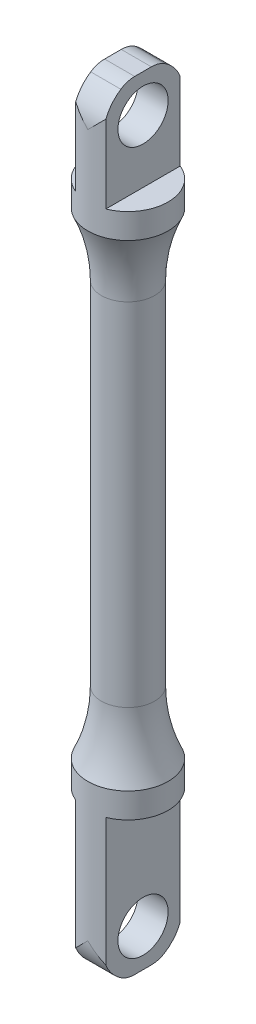
from build123d import *

# Parameters (mm, degrees)
BOSS_EXTRUDE1_DEPTH     = 20
BOSS_EXTRUDE2_DEPTH     = 30
SKETCH5_R               = 5
CUT_EXTRUDE1_DEPTH      = 6
CUT_EXTRUDE1_DEPTH_BACK = 12
FILLET6_R               = 5


with BuildPart() as part:
    # Sketch1 → Revolve1 (revolve)
    with BuildSketch(Plane.XY, mode=Mode.PRIVATE) as revolve1_sk:
        with BuildLine():
            Line((0, 0), (0, -52.5))
            Line((0, -52.5), (8, -52.5))
            Line((8, -52.5), (8, -47.5))
            ThreePointArc((8, -47.5), (5.982694721, -41.39413794), (5.3, -35))
            Line((5.3, -35), (5.3, 0))
            Line((5.3, 0), (0, 0))
        make_face()
    revolve1 = revolve(revolve1_sk.sketch.rotate(Axis((0, 0, 0), (0, -1, 0)), 180), axis=Axis((0, 0, 0), (0, -1, 0)))  # turned: the seam where the file's is

    # Mirror1: Revolve1 across plane
    add(revolve1.mirror(Plane(origin=(5.3, 0, 0), x_dir=(0, 0, 1), z_dir=(0, -1, 0))))

    # Sketch3 → Boss-Extrude1 (add)
    with BuildSketch(Plane(origin=(0, 52.5, 0), x_dir=(1, 0, 0), z_dir=(0, 1, 0))):
        with BuildLine():
            Line((-3, 7.416198487), (-3, -7.416198487))
            ThreePointArc((-3, -7.416198487), (0, -8), (3, -7.416198487))
            Line((3, -7.416198487), (3, 7.416198487))
            ThreePointArc((3, 7.416198487), (0, 8), (-3, 7.416198487))
        make_face()
    extrude(amount=BOSS_EXTRUDE1_DEPTH)

    # Sketch4 → Boss-Extrude2 (add)
    with BuildSketch(Plane.XZ.offset(52.5)):
        with BuildLine():
            Line((3, 7.416198487), (3, -7.416198487))
            ThreePointArc((3, -7.416198487), (0, -8), (-3, -7.416198487))
            Line((-3, -7.416198487), (-3, 7.416198487))
            ThreePointArc((-3, 7.416198487), (0, 8), (3, 7.416198487))
        make_face()
    extrude(amount=BOSS_EXTRUDE2_DEPTH)

    # Sketch5 → Cut-Extrude1 (cut, two sides)
    with BuildSketch(Plane.ZY.offset(3)) as cut_extrude1_sk:
        with Locations(Location((0, 65, 0), (0, 0, 270))):  # turned: the seam where the file's is
            Circle(SKETCH5_R)
        with Locations(Location((0, -75, 0), (0, 0, 270))):  # turned: the seam where the file's is
            Circle(SKETCH5_R)
        with BuildLine():
            Line((-18.407176047, 86.225483422), (21.713257403, 86.225483422))
            Line((21.713257403, 86.225483422), (21.713257403, 65))
            Line((21.713257403, 65), (8, 65))
            ThreePointArc((8, 65), (0, 73), (-8, 65))
            Line((-8, 65), (-18.407176047, 65))
            Line((-18.407176047, 65), (-18.407176047, 86.225483422))
        make_face()
        with BuildLine():
            Line((21.713257403, -75), (8, -75))
            ThreePointArc((8, -75), (0, -83), (-8, -75))
            Line((-8, -75), (-18.407176047, -75))
            Line((-18.407176047, -75), (-18.407176047, -89.54271926))
            Line((-18.407176047, -89.54271926), (21.713257403, -89.54271926))
            Line((21.713257403, -89.54271926), (21.713257403, -75))
        make_face()
    extrude(amount=CUT_EXTRUDE1_DEPTH, mode=Mode.SUBTRACT)
    extrude(cut_extrude1_sk.sketch, amount=-CUT_EXTRUDE1_DEPTH_BACK, mode=Mode.SUBTRACT)

    # Fillet6
    fillet6_edges = [part.edges().sort_by_distance(p)[0] for p in [
        (0, -82.5, 2.783882181),
        (0, -82.5, -2.783882181),
        (0, 72.5, 2.783882181),
        (0, 72.5, -2.783882181),
    ]]
    fillet(fillet6_edges, radius=FILLET6_R)


solid = part.part
